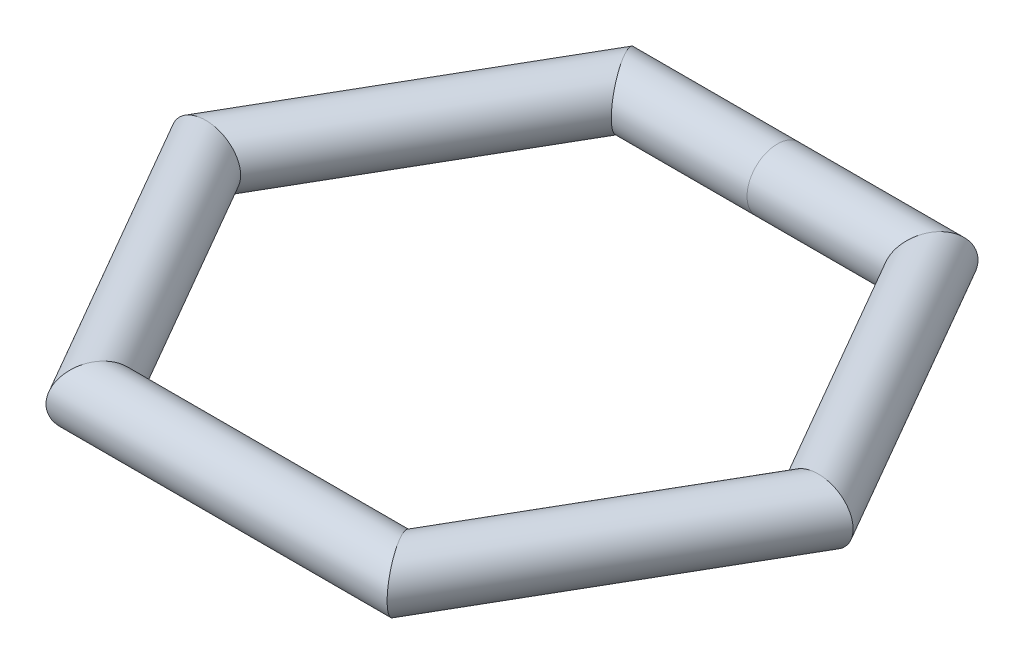
from build123d import *

# Parameters (mm, degrees)
SKETCH2_R = 8.107303668


with BuildPart() as part:
    # Sweep1: sweep along a path in Sketch1
    with BuildLine(Plane(origin=(0, 0, 0), x_dir=(1, 0, 0), z_dir=(0, 1, 0))) as sweep1_path:
        Line((41.095076423, 71.178760306), (-41.095076423, 71.178760306))
        Line((-41.095076423, 71.178760306), (-82.190152847, 0))
        Line((-82.190152847, 0), (-41.095076423, -71.178760306))
        Line((-41.095076423, -71.178760306), (41.095076423, -71.178760306))
        Line((41.095076423, -71.178760306), (82.190152847, 0))
        Line((82.190152847, 0), (41.095076423, 71.178760306))
    # Sketch2 → Sweep1 (sweep)
    with BuildSketch(Plane(origin=(0, 0, 0), x_dir=(0, 0, -1), z_dir=(1, 0, 0))):
        with Locations((71.178760306, 0)):
            Circle(SKETCH2_R)
    sweep(path=sweep1_path.line, transition=Transition.RIGHT)


solid = part.part
